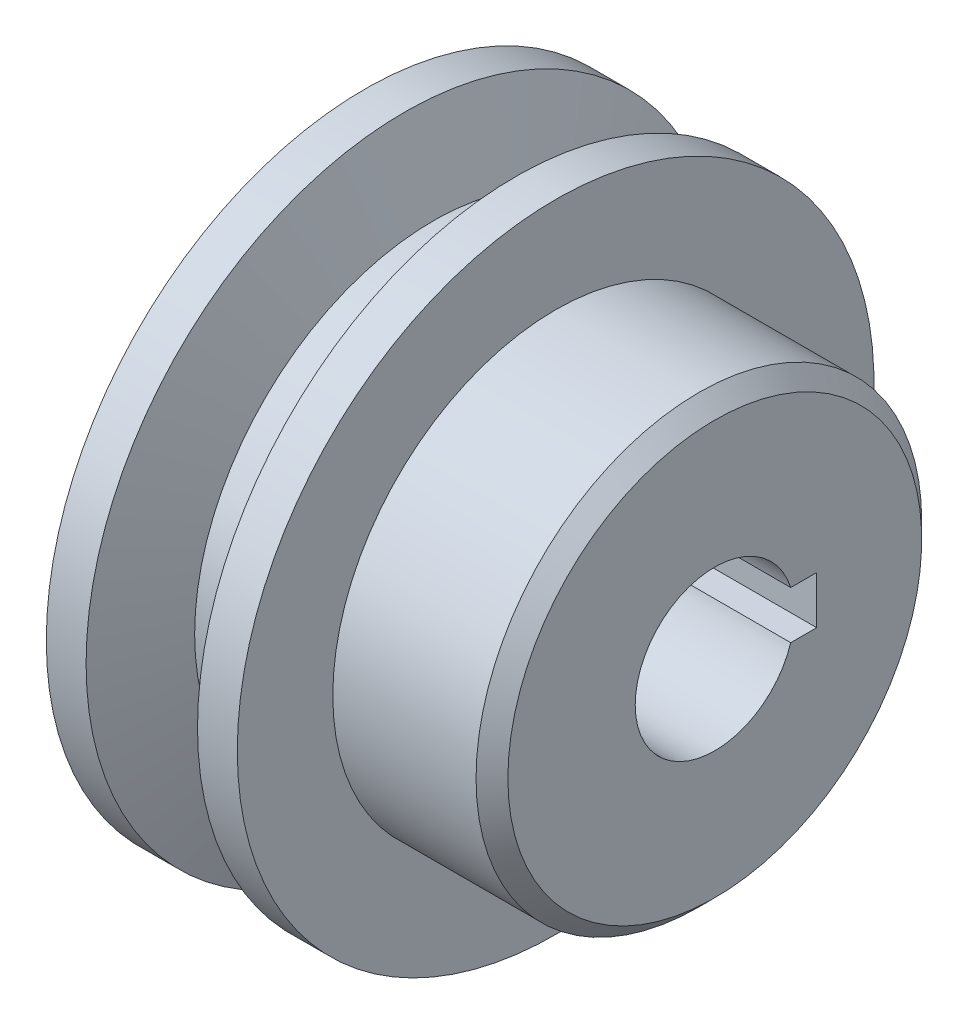
from build123d import *

# Parameters (mm, degrees)
CUT_EXTRUDE1_DEPTH = 23
CHAMFER1_SIZE      = 1


with BuildPart() as part:
    # Sketch2 → Revolve1 (revolve)
    with BuildSketch(Plane.XY):
        Polygon((0, 0), (22, 0), (22, 14), (12, 14), (12, 20), (9.5, 20), (7.680148663, 15), (4.319851044, 15), (2.5, 20.000000107), (0, 20.000000107), align=None)
    revolve(axis=Axis((0, 0, 0), (1, 0, 0)))

    # Sketch3 → Cut-Extrude1 (cut, through all)
    with BuildSketch(Plane(origin=(22, 0, 0), x_dir=(0, 0, -1), z_dir=(1, 0, 0))):
        with BuildLine():
            Line((6.4, 1.5), (6.4, -1.5))
            Line((6.4, -1.5), (4.769696007, -1.5))
            ThreePointArc((4.769696007, -1.5), (-5, 0), (4.769696007, 1.5))
            Line((4.769696007, 1.5), (6.4, 1.5))
        make_face()
    extrude(amount=-CUT_EXTRUDE1_DEPTH, mode=Mode.SUBTRACT)

    # Chamfer1
    chamfer1_edges = [part.edges().sort_by_distance(p)[0] for p in [
        (22, -14, 0),
    ]]
    chamfer(chamfer1_edges, length=CHAMFER1_SIZE)


solid = part.part
